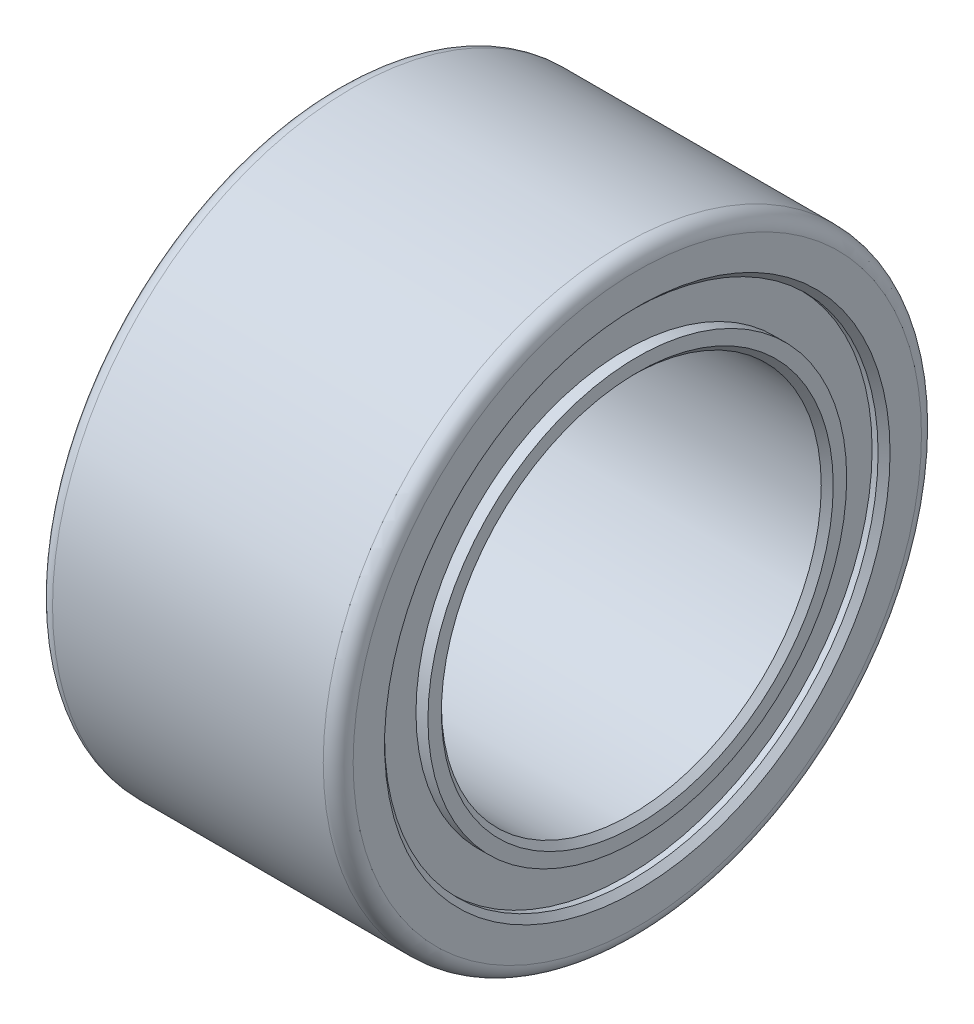
from build123d import *

# Parameters (mm, degrees)
SKETCH2_R           = 5
BOSS_EXTRUDE1_DEPTH = 2.4892
SKETCH3_R           = 3.175
CUT_EXTRUDE1_DEPTH  = 5.9784
SKETCH4_R           = 4.125
SKETCH4_R_2         = 3.5
CUT_EXTRUDE2_DEPTH  = 0.2
CHAMFER1_SIZE       = 0.1
FILLET1_R           = 0.25


with BuildPart() as part:
    # Sketch2 → Boss-Extrude1 (new body, symmetric)
    with BuildSketch(Plane(origin=(0, 0, 0), x_dir=(0, 0, -1), z_dir=(1, 0, 0))):
        Circle(SKETCH2_R)
    extrude(amount=BOSS_EXTRUDE1_DEPTH, both=True)

    # Sketch3 → Cut-Extrude1 (cut, through all)
    with BuildSketch(Plane(origin=(2.4892, 0, 0), x_dir=(0, 0, -1), z_dir=(1, 0, 0))):
        Circle(SKETCH3_R)
    extrude(amount=-CUT_EXTRUDE1_DEPTH, mode=Mode.SUBTRACT)

    # Sketch4 → Cut-Extrude2 (cut)
    with BuildSketch(Plane(origin=(2.4892, 0, 0), x_dir=(0, 0, -1), z_dir=(1, 0, 0))):
        Circle(SKETCH4_R)
        Circle(SKETCH4_R_2, mode=Mode.SUBTRACT)
    cut_extrude2 = extrude(amount=-CUT_EXTRUDE2_DEPTH, mode=Mode.SUBTRACT)

    # Mirror1: Cut-Extrude2 across plane
    add(cut_extrude2.mirror(Plane(origin=(0, 0, 0), x_dir=(0, 0, 1), z_dir=(1, 0, 0))), mode=Mode.SUBTRACT)

    # Chamfer1
    chamfer1_edges = [part.edges().sort_by_distance(p)[0] for p in [
        (2.4892, 0, 4.125),
        (-2.4892, 0, 5),
        (-2.4892, 0, 3.175),
        (2.4892, 0, 3.175),
    ]]
    chamfer(chamfer1_edges, length=CHAMFER1_SIZE)

    # Fillet1
    fillet1_edges = [part.edges().sort_by_distance(p)[0] for p in [
        (-2.3892, 0, 5),
        (2.4892, 0, 5),
    ]]
    fillet(fillet1_edges, radius=FILLET1_R)


solid = part.part
